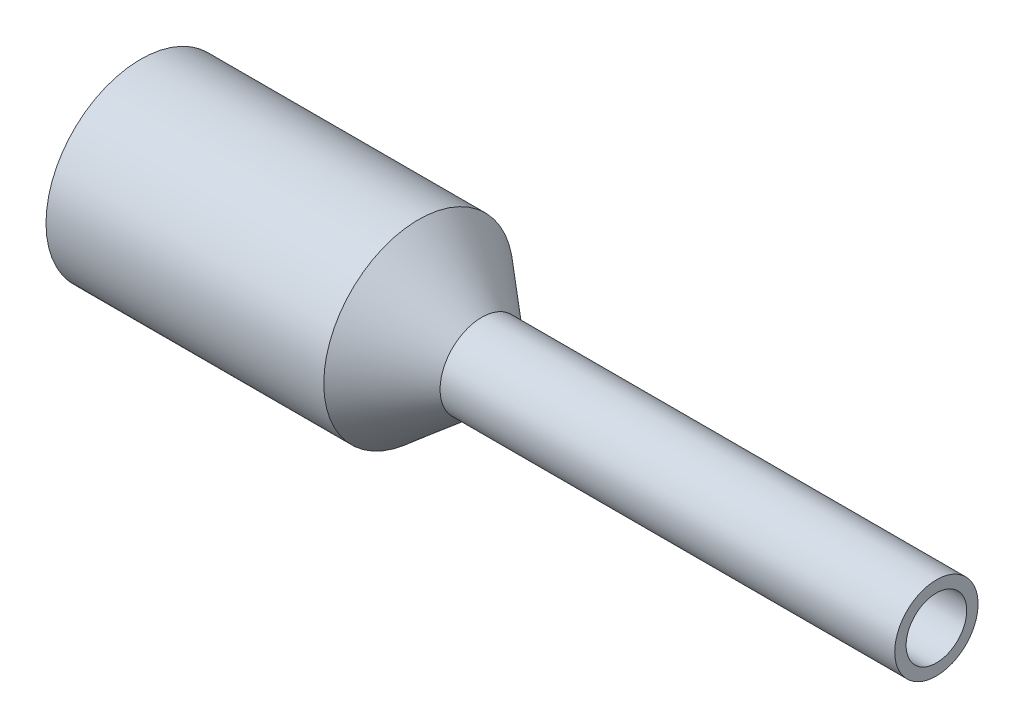
from build123d import *


with BuildPart() as part:
    # Croquis1 → Revolución1 (revolve)
    with BuildSketch(Plane.XY):
        Polygon((5.25, 0.4), (-0.75, 0.4), (-1.584227515, 1), (-5.25, 1), (-5.25, 1.25), (-1.584227515, 1.25), (-0.75, 0.55), (5.25, 0.55), align=None)
    revolve(axis=Axis((-5.25, 0, 0), (1, 0, 0)))


solid = part.part
